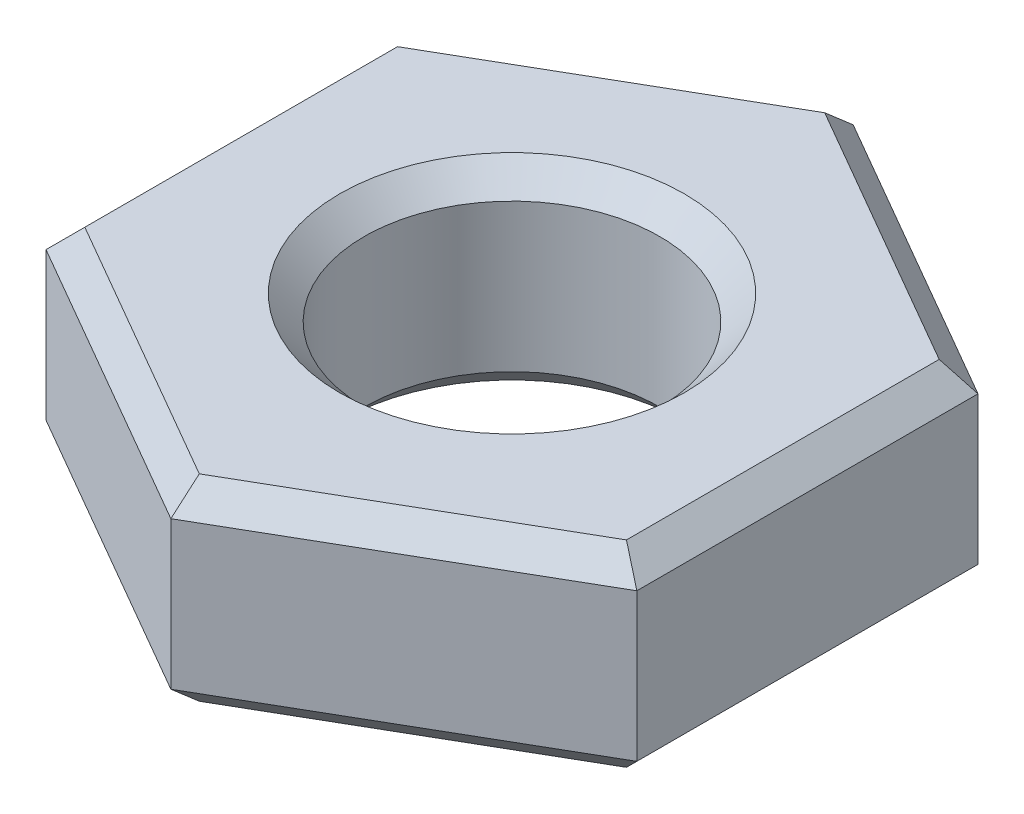
from build123d import *

# Parameters (mm, degrees)
SKETCH1_R           = 1.5
BOSS_EXTRUDE1_DEPTH = 2
CHAMFER1_SIZE       = 0.25


with BuildPart() as part:
    # Sketch1 → Boss-Extrude1 (new body)
    with BuildSketch(Plane(origin=(0, 0, 0), x_dir=(1, 0, 0), z_dir=(0, 1, 0))):
        Polygon((0, -3.464101615), (3, -1.732050808), (3, 1.732050808), (0, 3.464101615), (-3, 1.732050808), (-3, -1.732050808), align=None)
        Circle(SKETCH1_R, mode=Mode.SUBTRACT)
    extrude(amount=BOSS_EXTRUDE1_DEPTH)

    # Chamfer1
    chamfer1_edges = [part.edges().sort_by_distance(p)[0] for p in [
        (3, 2, 0),
        (1.5, 2, -2.598076211),
        (-1.5, 0, 0),
        (-1.5, 2, 0),
        (-1.5, 2, -2.598076211),
        (-3, 2, 0),
        (-1.5, 2, 2.598076211),
        (-3, 0, 0),
        (-1.5, 0, -2.598076211),
        (1.5, 0, -2.598076211),
        (3, 0, 0),
        (1.5, 0, 2.598076211),
        (-1.5, 0, 2.598076211),
        (1.5, 2, 2.598076211),
    ]]
    chamfer(chamfer1_edges, length=CHAMFER1_SIZE)


solid = part.part
